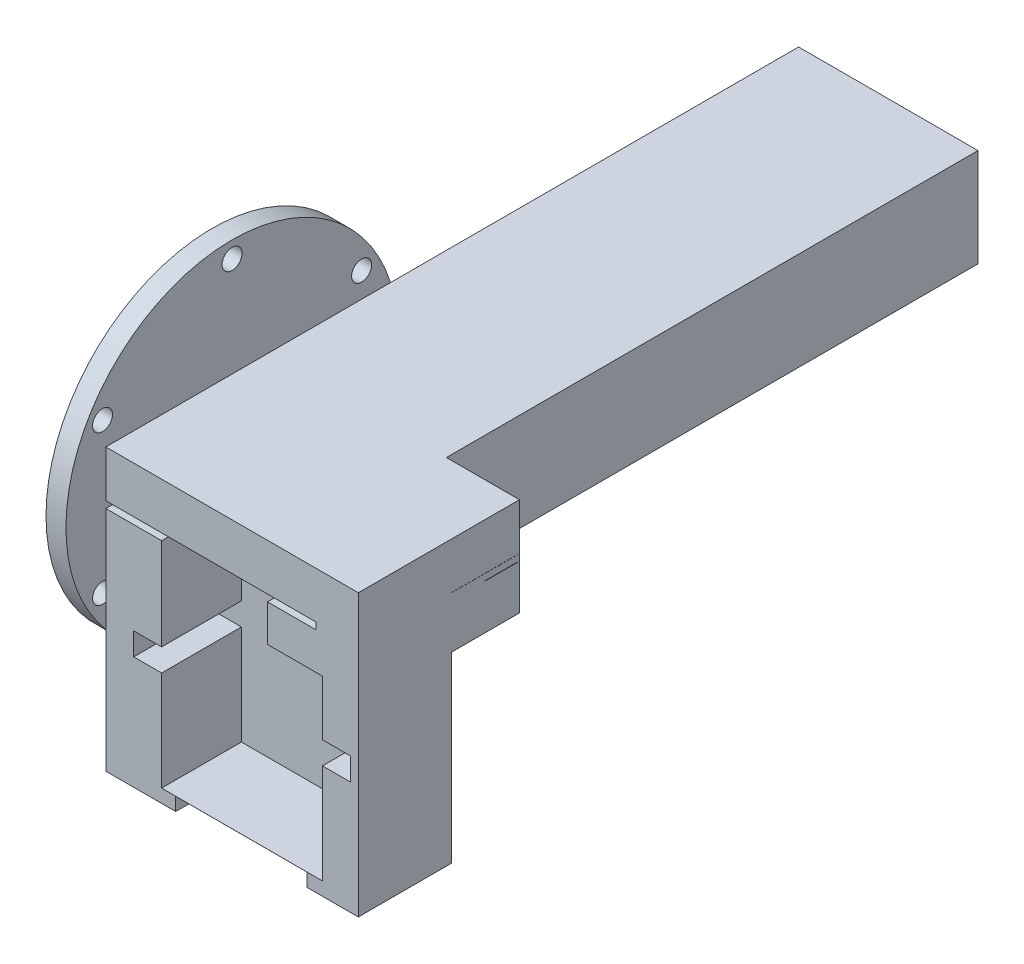
from build123d import *

# Parameters (mm, degrees)
EXTRUDE_1_DEPTH     = 14
SKETCH_3_W          = 34.989164417
SKETCH_3_H          = 23.7
EXTRUDE_2_DEPTH     = 1.99
SKETCH_4_W          = 19.73952378
SKETCH_4_H          = 14
CUT_EXTRUDE_1_DEPTH = 1.99
EXTRUDE_3_DEPTH     = 4.99
EXTRUDE_4_DEPTH     = 5.55
EXTRUDE_5_DEPTH     = 1.02
SKETCH_13_W         = 35
SKETCH_13_H         = 14
EXTRUDE_6_DEPTH     = 4
EXTRUDE_8_DEPTH     = 21
SKETCH_15_W         = 5
SKETCH_15_H         = 5.74
SKETCH_15_H_2       = 4
EXTRUDE_9_DEPTH     = 14
EXTRUDE_10_DEPTH    = 1
SKETCH_17_W         = 35
SKETCH_17_H         = 19
EXTRUDE_11_DEPTH    = 3
SKETCH_18_W         = 35
SKETCH_18_H         = 5
EXTRUDE_12_DEPTH    = 1
EXTRUDE_16_DEPTH    = 3
SKETCH_20_W         = 5.25
SKETCH_20_H         = 3.26
SKETCH_20_H_2       = 3
EXTRUDE_18_DEPTH    = 35
SKETCH_21_W         = 14
SKETCH_21_H         = 3.74
SKETCH_21_H_2       = 3.75
EXTRUDE_19_DEPTH    = 5
EXTRUDE_20_DEPTH    = 11
SKETCH_26_W         = 0.25
SKETCH_26_H         = 8.5
EXTRUDE_21_DEPTH    = 3
SKETCH_27_W         = 21
SKETCH_27_H         = 8.5
EXTRUDE_22_DEPTH    = 80
SKETCH_28_R         = 25
SKETCH_28_R_2       = 6
SKETCH_28_R_3       = 1.5
EXTRUDE_23_DEPTH    = 3


with BuildPart() as part:
    # 草图2 → 凸台-拉伸1 (new body)
    with BuildSketch(Plane.XY.offset(6)):
        Polygon((58.617261146, 15.562420382), (53.219585402, 15.562420382), (53.219585402, 12.262420382), (57.419585402, 12.262420382), (57.419585402, 8.862420382), (53.219585402, 8.862420382), (53.219585402, -6.137579618), (29.014936891, -6.137579618), (29.014936891, 8.862420382), (24.814936891, 8.862420382), (24.814936891, 12.262420382), (29.014936891, 12.262420382), (29.014936891, 15.562420382), (23.617261146, 15.562420382), (23.617261146, -8.137579618), (58.617261146, -8.137579618), align=None)
    extrude(amount=-EXTRUDE_1_DEPTH)

    # 草图3 → 凸台-拉伸2 (add)
    with BuildSketch(Plane(origin=(0, 0, -8), x_dir=(-1, 0, 0), z_dir=(0, 0, -1))):
        with Locations((-41.122678938, 3.712420382)):
            Rectangle(SKETCH_3_W, SKETCH_3_H)
    extrude(amount=-EXTRUDE_2_DEPTH)

    # 草图4 → 切除-拉伸1 (cut)
    with BuildSketch(Plane.XZ.offset(8.137579618)):
        with Locations((41.002259963, -1)):
            Rectangle(SKETCH_4_W, SKETCH_4_H)
    extrude(amount=-CUT_EXTRUDE_1_DEPTH, mode=Mode.SUBTRACT)

    # 草图7 → 凸台-拉伸3 (add)
    with BuildSketch(Plane(origin=(0, 15.562420382, 0), x_dir=(1, 0, 0), z_dir=(0, 1, 0))):
        Polygon((29.014936891, -6), (23.617261146, -6), (23.617261146, 8), (58.617261146, 8), (58.617261146, -6), (53.219585402, -6), (53.219585402, 6.01), (29.014936891, 6.01), align=None)
    extrude(amount=EXTRUDE_3_DEPTH)

    # 草图8 → 凸台-拉伸4 (add)
    with BuildSketch(Plane(origin=(0, 20.552420382, 0), x_dir=(1, 0, 0), z_dir=(0, 1, 0))):
        Polygon((23.617261146, -6), (29.014936891, -6), (29.014936891, 6.01), (44.953536614, 6.01), (44.953536614, -6), (58.617261146, -6), (58.617261146, 8), (23.617261146, 8), align=None)
    extrude(amount=EXTRUDE_4_DEPTH)

    # 草图11 → 凸台-拉伸5 (add)
    with BuildSketch(Plane(origin=(0, 26.102420382, 0), x_dir=(1, 0, 0), z_dir=(0, 1, 0))):
        with BuildLine():
            Line((51.35010895, 8), (58.617261146, 8))
            Line((58.617261146, 8), (58.617261146, -6))
            Line((58.617261146, -6), (52.21613159, -6))
            ThreePointArc((52.21613159, -6), (53.233588834, 1.089724187), (51.35010895, 8))
        make_face()
    extrude(amount=EXTRUDE_5_DEPTH)

    # 草图13 → 凸台-拉伸6 (add)
    with BuildSketch(Plane(origin=(0, 27.122420382, 0), x_dir=(1, 0, 0), z_dir=(0, 1, 0))):
        with Locations((41.117261146, 1)):
            Rectangle(SKETCH_13_W, SKETCH_13_H)
    extrude(amount=EXTRUDE_6_DEPTH)

    # 草图14 → 凸台-拉伸8 (add)
    with BuildSketch(Plane.ZY.offset(-23.617261146)):
        with BuildLine():
            Line((-8.78071096, 27.122420382), (-8, 27.122420382))
            Line((-8, 27.122420382), (-8, 31.122420382))
            Line((-8, 31.122420382), (-13, 31.122420382))
            Line((-13, 31.122420382), (-13, 30.862420382))
            ThreePointArc((-13, 30.862420382), (-10.180868928, 29.792829161), (-8.78071096, 27.122420382))
        make_face()
        with BuildLine():
            Line((-8, 26.102420382), (-8.78071096, 26.102420382))
            ThreePointArc((-8.78071096, 26.102420382), (-10.180868928, 23.432011603), (-13, 22.362420382))
            Line((-13, 22.362420382), (-13, 20.362420382))
            Line((-13, 20.362420382), (-8, 20.362420382))
            Line((-8, 20.362420382), (-8, 26.102420382))
        make_face()
    extrude(amount=-EXTRUDE_8_DEPTH)

    # 草图15 → 凸台-拉伸9 (add)
    with BuildSketch(Plane(origin=(44.617261146, 0, 0), x_dir=(0, 0, -1), z_dir=(1, 0, 0))):
        with Locations((10.5, 23.232420382)):
            Rectangle(SKETCH_15_W, SKETCH_15_H)
        with Locations((10.5, 29.122420382)):
            Rectangle(SKETCH_15_W, SKETCH_15_H_2)
    extrude(amount=EXTRUDE_9_DEPTH)

    # 草图16 → 凸台-拉伸10 (add)
    with BuildSketch(Plane(origin=(0, 26.102420382, 0), x_dir=(1, 0, 0), z_dir=(0, 1, 0))):
        with BuildLine():
            Line((47.481493106, 13), (58.617261146, 13))
            Line((58.617261146, 13), (58.617261146, 8))
            Line((58.617261146, 8), (51.2939955, 8))
            ThreePointArc((51.2939955, 8), (49.612839247, 10.671635002), (47.481493106, 13))
        make_face()
    extrude(amount=EXTRUDE_10_DEPTH)

    # 草图17 → 凸台-拉伸11 (add)
    with BuildSketch(Plane(origin=(0, 31.122420382, 0), x_dir=(1, 0, 0), z_dir=(0, 1, 0))):
        with Locations((41.117261146, 3.5)):
            Rectangle(SKETCH_17_W, SKETCH_17_H)
    extrude(amount=EXTRUDE_11_DEPTH)

    # 草图18 → 凸台-拉伸12 (add)
    with BuildSketch(Plane.XZ.offset(-20.362420382)):
        with Locations((41.117261146, -10.5)):
            Rectangle(SKETCH_18_W, SKETCH_18_H)
    extrude(amount=EXTRUDE_12_DEPTH)

    # 草图19 → 凸台-拉伸16 (add)
    with BuildSketch(Plane.ZY.offset(-23.617261146)):
        with BuildLine():
            Line((-8, 19.362420382), (-8, -8.137579618))
            Line((-8, -8.137579618), (6, -8.137579618))
            Line((6, -8.137579618), (6, 26.102420382))
            Line((6, 26.102420382), (-8.78071096, 26.102420382))
            ThreePointArc((-8.78071096, 26.102420382), (-17.25, 26.612420382), (-8.78071096, 27.122420382))
            Line((-8.78071096, 27.122420382), (6, 27.122420382))
            Line((6, 27.122420382), (6, 34.122420382))
            Line((6, 34.122420382), (-18.25, 34.122420382))
            Line((-18.25, 34.122420382), (-18.25, 19.362420382))
            Line((-18.25, 19.362420382), (-8, 19.362420382))
        make_face()
    extrude(amount=EXTRUDE_16_DEPTH)

    # 草图20 → 凸台-拉伸18 (add)
    with BuildSketch(Plane(origin=(23.617261146, 0, 0), x_dir=(0, 0, -1), z_dir=(1, 0, 0))):
        with Locations((15.625, 32.492420382)):
            Rectangle(SKETCH_20_W, SKETCH_20_H)
        with Locations((15.625, 20.862420382)):
            Rectangle(SKETCH_20_W, SKETCH_20_H_2)
    extrude(amount=EXTRUDE_18_DEPTH)

    # 草图21 → 凸台-拉伸19 (add)
    with BuildSketch(Plane(origin=(0, 0, -13), x_dir=(-1, 0, 0), z_dir=(0, 0, -1))):
        with Locations((-51.617261146, 28.992420382)):
            Rectangle(SKETCH_21_W, SKETCH_21_H)
        with Locations((-51.617261146, 24.237420382)):
            Rectangle(SKETCH_21_W, SKETCH_21_H_2)
    extrude(amount=EXTRUDE_19_DEPTH)

    # 草图22 → 凸台-拉伸20 (add)
    with BuildSketch(Plane(origin=(58.617261146, 0, 0), x_dir=(0, 0, -1), z_dir=(1, 0, 0))):
        Polygon((18, 27.102420382), (13, 27.102420382), (13, 26.155844896), (18, 26.155844896), (18, 22.362420382), (18.25, 22.362420382), (18.25, 30.862420382), (18, 30.862420382), align=None)
    extrude(amount=-EXTRUDE_20_DEPTH)

    # 草图26 → 凸台-拉伸21 (add)
    with BuildSketch(Plane.ZY.offset(-47.617261146)):
        with Locations((-18.125, 26.612420382)):
            Rectangle(SKETCH_26_W, SKETCH_26_H)
    extrude(amount=EXTRUDE_21_DEPTH)

    # 草图27 → 凸台-拉伸22 (add)
    with BuildSketch(Plane(origin=(0, 0, -18.25), x_dir=(-1, 0, 0), z_dir=(0, 0, -1))):
        Polygon((-47.617261146, 34.122420382), (-47.617261146, 30.862420382), (-47.617261146, 19.362420382), (-20.617261146, 19.362420382), (-20.617261146, 34.122420382), align=None)
        with Locations((-34.117261146, 26.612420382)):
            Rectangle(SKETCH_27_W, SKETCH_27_H, mode=Mode.SUBTRACT)
    extrude(amount=EXTRUDE_22_DEPTH)

    # 草图28 → 凸台-拉伸23 (add)
    with BuildSketch(Plane.ZY.offset(-20.617261146)):
        with Locations((-13, 26.612420382)):
            Circle(SKETCH_28_R)
        with Locations((-13, 26.612420382)):
            Circle(SKETCH_28_R_2, mode=Mode.SUBTRACT)
        with Locations((-13, 4.102420382)):
            Circle(SKETCH_28_R_3, mode=Mode.SUBTRACT)
        with Locations((-32.494231839, 15.357420382)):
            Circle(SKETCH_28_R_3, mode=Mode.SUBTRACT)
        with Locations((-32.494231839, 37.867420382)):
            Circle(SKETCH_28_R_3, mode=Mode.SUBTRACT)
        with Locations((-13, 49.122420382)):
            Circle(SKETCH_28_R_3, mode=Mode.SUBTRACT)
        with Locations((6.494231839, 37.867420382)):
            Circle(SKETCH_28_R_3, mode=Mode.SUBTRACT)
        with Locations((6.494231839, 15.357420382)):
            Circle(SKETCH_28_R_3, mode=Mode.SUBTRACT)
    extrude(amount=EXTRUDE_23_DEPTH)


solid = part.part
